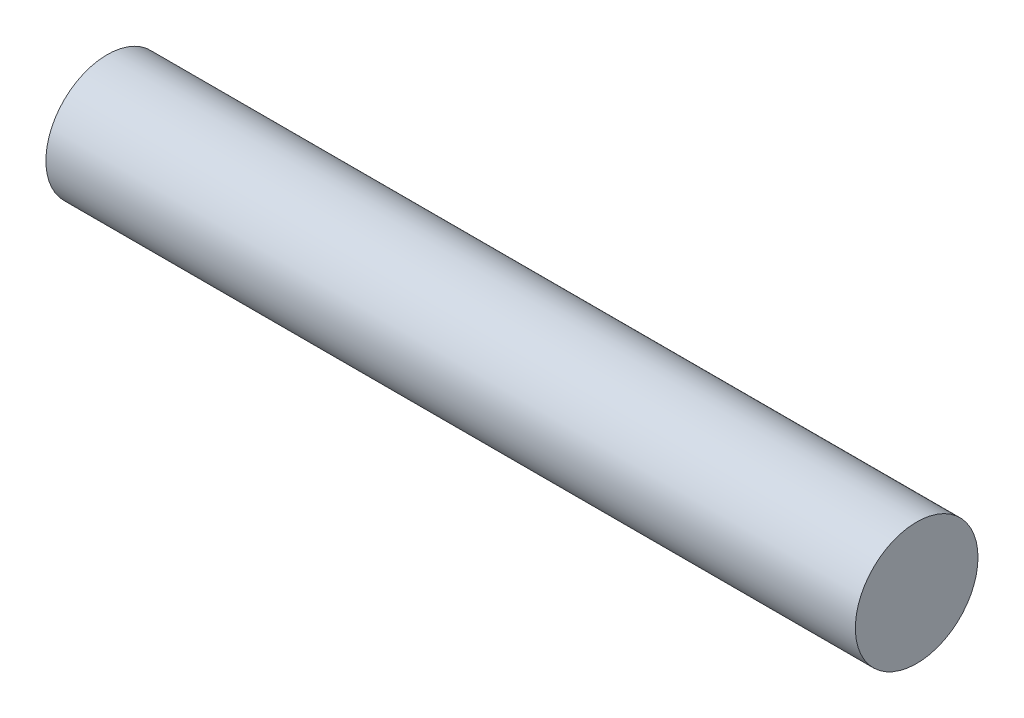
from build123d import *

# Parameters (mm, degrees)
SKETCH1_R           = 3.175
BOSS_EXTRUDE1_DEPTH = 41.91


with BuildPart() as part:
    # Sketch1 → Boss-Extrude1 (new body)
    with BuildSketch(Plane(origin=(0, 0, 0), x_dir=(0, 0, -1), z_dir=(1, 0, 0))):
        Circle(SKETCH1_R)
    extrude(amount=BOSS_EXTRUDE1_DEPTH)


solid = part.part
